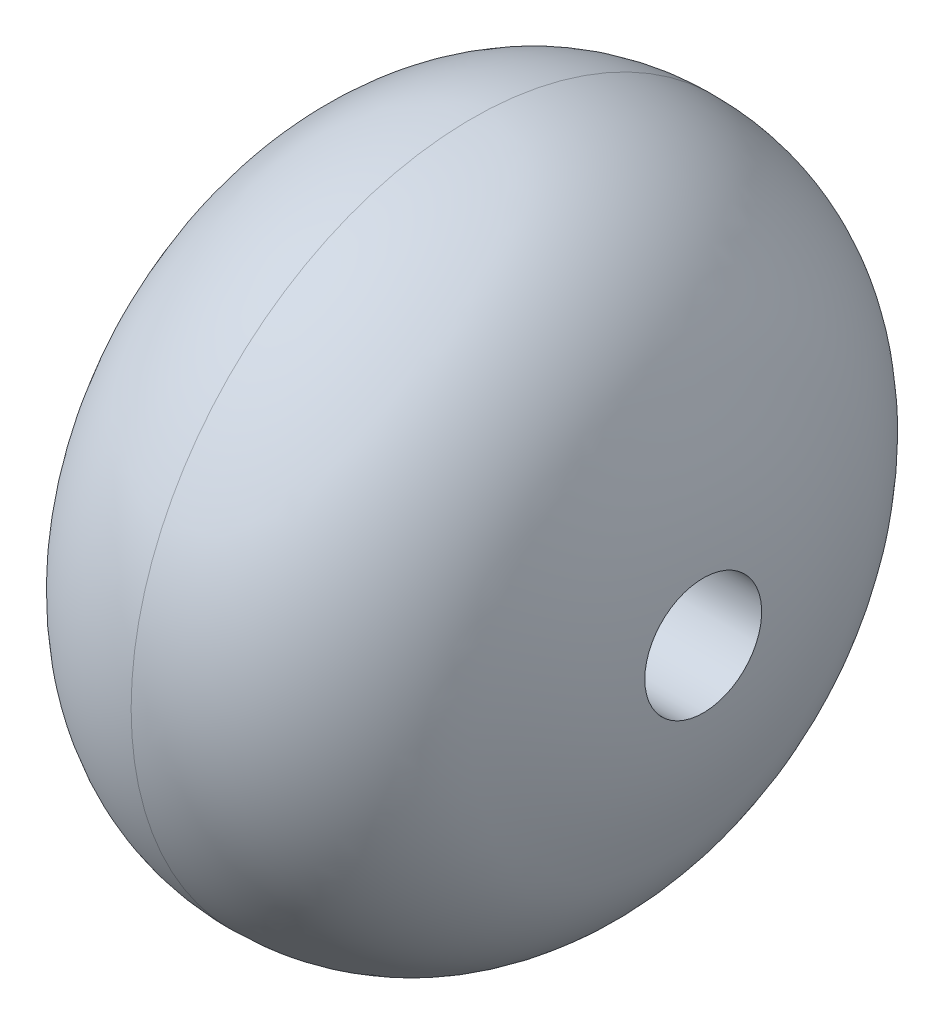
from build123d import *

# Parameters (mm, degrees)
ESQUISSE2_R                  = 3
ENL_V_MAT_EXTRU_1_DEPTH      = 13.0000001
ENL_V_MAT_EXTRU_1_DEPTH_BACK = 13.0000001


with BuildPart() as part:
    # Esquisse1 → Révolution1 (revolve)
    with BuildSketch(Plane.XY):
        with BuildLine():
            Line((-12, 0), (12, 0))
            add(Edge.make_bspline(
                [(12, 0), (12, 4.391177435), (11.165586865, 7.449208172), (8.820493883, 13.526257804), (5.056188258, 17.5), (0, 17.5)],
                knots=[0, 0, 0, 0, 0.473704328, 0.573704328, 1, 1, 1, 1], degree=3))
            add(Edge.make_bspline(
                [(-12, 0), (-12, 4.391177435), (-11.165586865, 7.449208172), (-8.820493883, 13.526257804), (-5.056188258, 17.5), (0, 17.5)],
                knots=[0, 0, 0, 0, 0.473704328, 0.573704328, 1, 1, 1, 1], degree=3))
        make_face()
    revolve(axis=Axis((-12, 0, 0), (1, 0, 0)))

    # Esquisse2 → Enlèv. mat.-Extru.1 (cut, two sides)
    with BuildSketch(Plane(origin=(0, 0, 0), x_dir=(0, 0, -1), z_dir=(1, 0, 0))) as enl_v_mat_extru_1_sk:
        Circle(ESQUISSE2_R)
    extrude(amount=ENL_V_MAT_EXTRU_1_DEPTH, mode=Mode.SUBTRACT)
    extrude(enl_v_mat_extru_1_sk.sketch, amount=-ENL_V_MAT_EXTRU_1_DEPTH_BACK, mode=Mode.SUBTRACT)


solid = part.part
